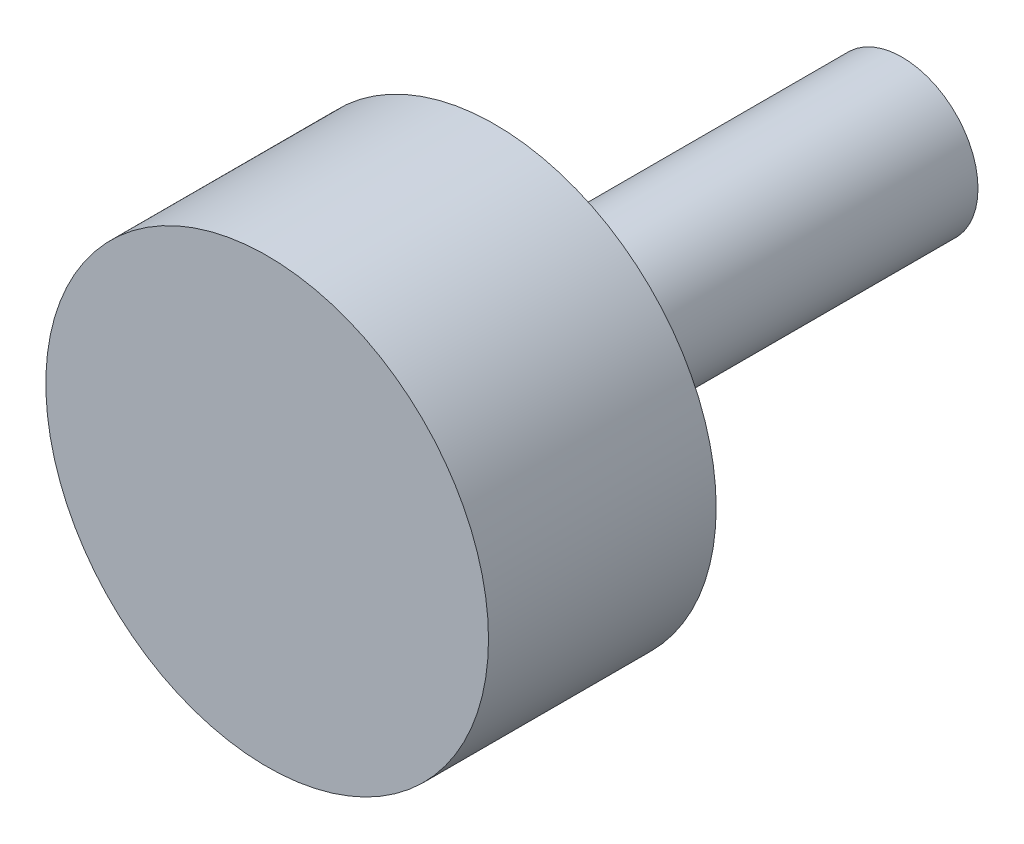
from build123d import *

# Parameters (mm, degrees)
SKETCH1_R           = 6
BOSS_EXTRUDE1_DEPTH = 32.2
SKETCH2_R           = 17.5
BOSS_EXTRUDE2_DEPTH = 18
SKETCH3_R           = 2.9
CUT_EXTRUDE1_DEPTH  = 18


with BuildPart() as part:
    # Sketch1 → Boss-Extrude1 (new body)
    with BuildSketch(Plane.XY):
        Circle(SKETCH1_R)
    extrude(amount=BOSS_EXTRUDE1_DEPTH)

    # Sketch2 → Boss-Extrude2 (add)
    with BuildSketch(Plane.XY.offset(32.2)):
        Circle(SKETCH2_R)
    extrude(amount=BOSS_EXTRUDE2_DEPTH)

    # Sketch3 → Cut-Extrude1 (cut)
    with BuildSketch(Plane(origin=(0, 0, 0), x_dir=(-1, 0, 0), z_dir=(0, 0, -1))):
        Circle(SKETCH3_R)
    extrude(amount=-CUT_EXTRUDE1_DEPTH, mode=Mode.SUBTRACT)


solid = part.part
